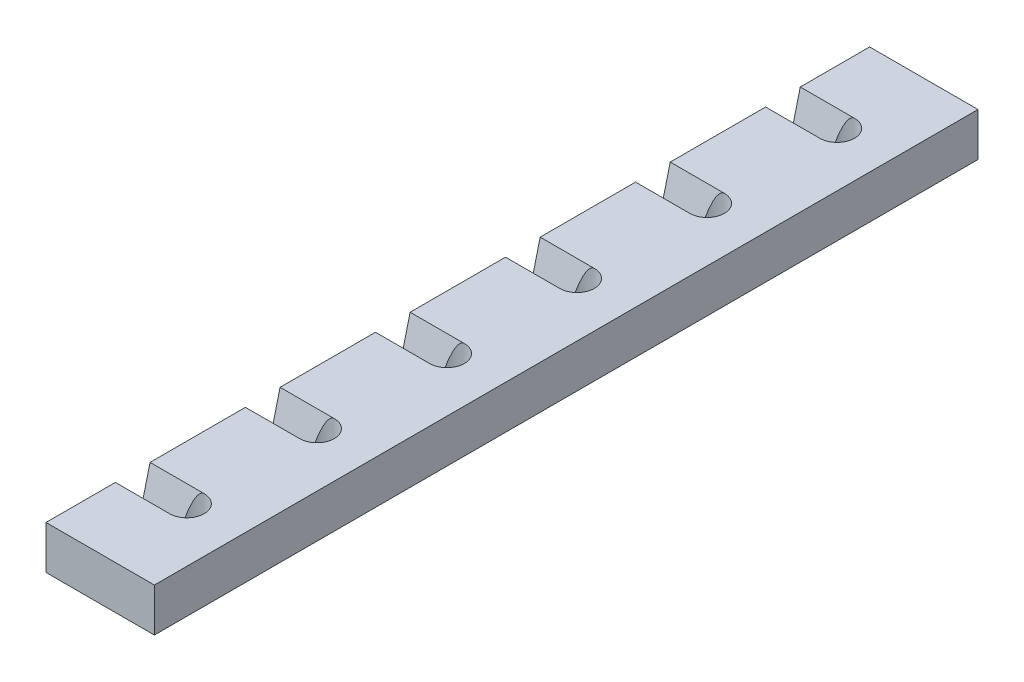
from build123d import *

# Parameters (mm, degrees)
SKETCH1_W           = 50
SKETCH1_H           = 20
BOSS_EXTRUDE1_DEPTH = 380
SKETCH2_R           = 8
CUT_EXTRUDE1_DEPTH  = 21
CUT_EXTRUDE2_REACH  = 52


with BuildPart() as part:
    # Sketch1 → Boss-Extrude1 (new body)
    with BuildSketch(Plane.XY):
        Rectangle(SKETCH1_W, SKETCH1_H)
    extrude(amount=-BOSS_EXTRUDE1_DEPTH)

    # Sketch2 → Cut-Extrude1 (cut, through all)
    with BuildSketch(Plane(origin=(0, 10, 0), x_dir=(1, 0, 0), z_dir=(0, 1, 0))):
        with Locations((0, 40)):
            Circle(SKETCH2_R)
        with Locations((0, 100)):
            Circle(SKETCH2_R)
        with Locations((0, 160)):
            Circle(SKETCH2_R)
        with Locations((0, 220)):
            Circle(SKETCH2_R)
        with Locations((0, 280)):
            Circle(SKETCH2_R)
        with Locations((0, 340)):
            Circle(SKETCH2_R)
    extrude(amount=-CUT_EXTRUDE1_DEPTH, mode=Mode.SUBTRACT)

    # Sketch3 → Cut-Extrude2 (cut, up to next)
    with BuildSketch(Plane.ZY.offset(25), mode=Mode.PRIVATE) as cut_extrude2_sk1:
        Polygon((-348, 10), (-343, -10), (-337, -10), (-332, 10), align=None)
    cut_extrude2_tool1 = extrude(cut_extrude2_sk1.sketch, amount=-CUT_EXTRUDE2_REACH, mode=Mode.PRIVATE) & part.part
    add(cut_extrude2_tool1.solids().sort_by_distance((-25, 1.515152, -340))[0], mode=Mode.SUBTRACT)
    # Sketch3 → Cut-Extrude2 (cut, up to next)
    with BuildSketch(Plane.ZY.offset(25), mode=Mode.PRIVATE) as cut_extrude2_sk2:
        Polygon((-288, 10), (-283, -10), (-277, -10), (-272, 10), align=None)
    cut_extrude2_tool2 = extrude(cut_extrude2_sk2.sketch, amount=-CUT_EXTRUDE2_REACH, mode=Mode.PRIVATE) & part.part
    add(cut_extrude2_tool2.solids().sort_by_distance((-25, 1.515152, -280))[0], mode=Mode.SUBTRACT)
    # Sketch3 → Cut-Extrude2 (cut, up to next)
    with BuildSketch(Plane.ZY.offset(25), mode=Mode.PRIVATE) as cut_extrude2_sk3:
        Polygon((-228, 10), (-223, -10), (-217, -10), (-212, 10), align=None)
    cut_extrude2_tool3 = extrude(cut_extrude2_sk3.sketch, amount=-CUT_EXTRUDE2_REACH, mode=Mode.PRIVATE) & part.part
    add(cut_extrude2_tool3.solids().sort_by_distance((-25, 1.515152, -220))[0], mode=Mode.SUBTRACT)
    # Sketch3 → Cut-Extrude2 (cut, up to next)
    with BuildSketch(Plane.ZY.offset(25), mode=Mode.PRIVATE) as cut_extrude2_sk4:
        Polygon((-168, 10), (-163, -10), (-157, -10), (-152, 10), align=None)
    cut_extrude2_tool4 = extrude(cut_extrude2_sk4.sketch, amount=-CUT_EXTRUDE2_REACH, mode=Mode.PRIVATE) & part.part
    add(cut_extrude2_tool4.solids().sort_by_distance((-25, 1.515152, -160))[0], mode=Mode.SUBTRACT)
    # Sketch3 → Cut-Extrude2 (cut, up to next)
    with BuildSketch(Plane.ZY.offset(25), mode=Mode.PRIVATE) as cut_extrude2_sk5:
        Polygon((-108, 10), (-103, -10), (-97, -10), (-92, 10), align=None)
    cut_extrude2_tool5 = extrude(cut_extrude2_sk5.sketch, amount=-CUT_EXTRUDE2_REACH, mode=Mode.PRIVATE) & part.part
    add(cut_extrude2_tool5.solids().sort_by_distance((-25, 1.515152, -100))[0], mode=Mode.SUBTRACT)
    # Sketch3 → Cut-Extrude2 (cut, up to next)
    with BuildSketch(Plane.ZY.offset(25), mode=Mode.PRIVATE) as cut_extrude2_sk6:
        Polygon((-48, 10), (-43, -10), (-37, -10), (-32, 10), align=None)
    cut_extrude2_tool6 = extrude(cut_extrude2_sk6.sketch, amount=-CUT_EXTRUDE2_REACH, mode=Mode.PRIVATE) & part.part
    add(cut_extrude2_tool6.solids().sort_by_distance((-25, 1.515152, -40))[0], mode=Mode.SUBTRACT)


solid = part.part
